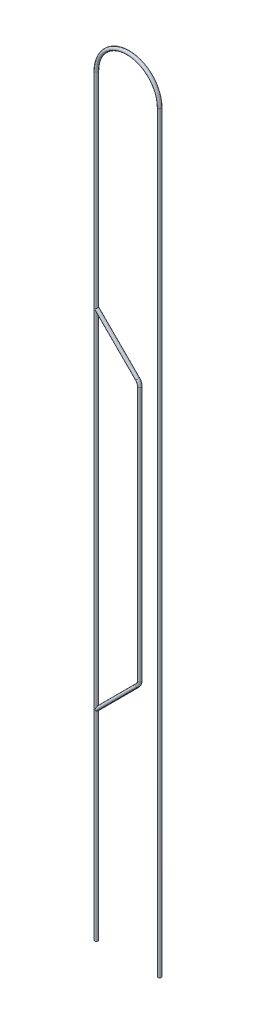
from build123d import *

# Parameters (mm, degrees)
SWEEP_THIN2_PROFILE_R   = 30.000000000000004
SWEEP_THIN2_PROFILE_R_2 = 27.000000000000004
SWEEP_THIN3_PROFILE_R   = 30.000000000000004
SWEEP_THIN3_PROFILE_R_2 = 27.000000000000004


with BuildPart() as part:
    # Sweep-Thin2: sweep along a curve in space
    with BuildLine() as sweep_thin2_path:
        Line((-22901.75870687505, -1725.8675310232888, 40706.600196056934), (-22901.75870687505, -1955.778677121315, 40706.600196057065))
        Line((-22901.75870687505, -1725.8675310232888, 40706.600196056934), (-22901.75870687505, 11702.425861660984, 40706.600196057065))
        ThreePointArc((-21754.061141737788, 11702.425861660984, 40706.600196057065), (-22327.90992430642, 12276.274644229616, 40706.60019605707), (-22901.75870687505, 11702.425861660984, 40706.600196057065))
        Line((-21754.061141738097, -1725.8675310232888, 40706.600196056934), (-21754.061141737788, 11702.425861660984, 40706.600196057065))
        Line((-21754.061141738097, -1725.8675310232888, 40706.600196056934), (-21754.061141737788, -1955.778677121315, 40706.600196057065))
    # Sweep-Thin2 profile (on start of the path) → Sweep-Thin2 (sweep)
    with BuildSketch(Plane(origin=(-21754.061141737788, -1955.778677121315, 40706.600196057065), x_dir=(1.0, 1.3449900270209231e-12, 0), z_dir=(-1.3449900270209231e-12, 1.0, -5.696428349735674e-13))):
        Circle(SWEEP_THIN2_PROFILE_R)
        Circle(SWEEP_THIN2_PROFILE_R_2, mode=Mode.SUBTRACT)
    sweep(path=sweep_thin2_path.line)

    # Sweep-Thin3: sweep along a curve in space
    with BuildLine() as sweep_thin3_path:
        Line((-22901.75870687505, 7983.118242776124, 40706.600196058156), (-22154.87516946897, 7236.234705370039, 40706.600196058105))
        ThreePointArc((-22114.774620219163, 7139.423415512547, 40706.6001960581), (-22125.19641341675, 7191.8173080335455, 40706.6001960581), (-22154.87516946897, 7236.234705370039, 40706.600196058105))
        Line((-22114.774620219163, 7139.423415512547, 40706.6001960581), (-22114.77462021917, 2516.6272302420525, 40706.60019605818))
        ThreePointArc((-22154.875169468974, 2419.8159403845602, 40706.60019605818), (-22125.196413416754, 2464.2333377210543, 40706.60019605818), (-22114.77462021917, 2516.6272302420525, 40706.60019605818))
        Line((-22154.875169468974, 2419.8159403845602, 40706.60019605818), (-22901.75870687505, 1672.9324029784834, 40706.600196058156))
    # Sweep-Thin3 profile (on start of the path) → Sweep-Thin3 (sweep)
    with BuildSketch(Plane(origin=(-22901.75870687505, 7983.118242776124, 40706.600196058156), x_dir=(-0.7071067811865501, -0.7071067811865449, 0), z_dir=(0.7071067811865449, -0.7071067811865501, -4.8219234963166634e-14))):
        Circle(SWEEP_THIN3_PROFILE_R)
        Circle(SWEEP_THIN3_PROFILE_R_2, mode=Mode.SUBTRACT)
    sweep(path=sweep_thin3_path.line)


solid = part.part
